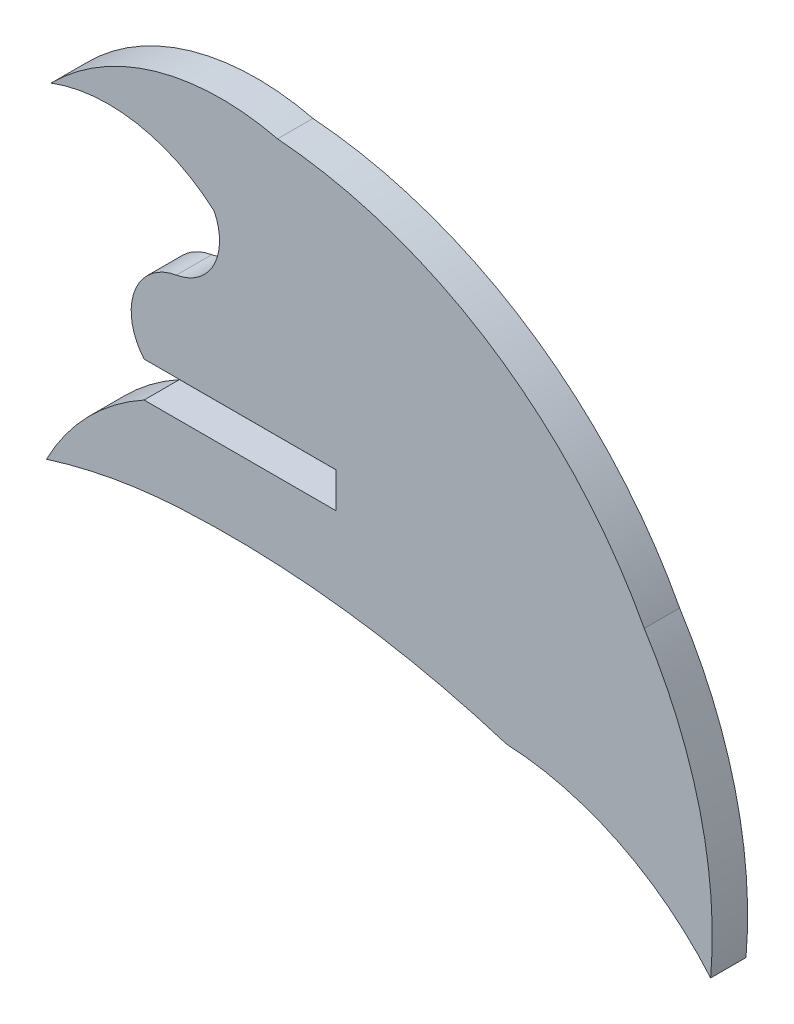
from build123d import *

# Parameters (mm, degrees)
BOSS_EXTRUDE1_DEPTH = 1.524


with BuildPart() as part:
    # Sketch1 → Boss-Extrude1 (new body)
    with BuildSketch(Plane.XY):
        with BuildLine():
            Line((-10.900934465, -3.68364082), (-2.635951713, -3.681036987))
            Line((-2.635951713, -3.681036987), (-2.635951713, -2.155055787))
            Line((-2.635951713, -2.155055787), (-10.901683213, -2.157042615))
            ThreePointArc((-10.901683213, -2.157042615), (-11.317544758, 0.15997729), (-9.511729503, 1.670127391))
            ThreePointArc((-9.511729503, 1.670127391), (-7.892680295, 2.86711895), (-7.885754316, 4.88058888))
            ThreePointArc((-7.885754316, 4.88058888), (-11.223059029, 6.479724486), (-14.907398818, 6.132625428))
            ThreePointArc((-14.907398818, 6.132625428), (-10.400280149, 8.822736649), (-5.152538869, 8.932411295))
            ThreePointArc((-5.152538869, 8.932411295), (4.07543143, 5.777326615), (10.640409761, -1.4345424))
            ThreePointArc((10.640409761, -1.4345424), (13.031939874, -7.001943531), (13.500316897, -13.04313502))
            ThreePointArc((13.500316897, -13.04313502), (9.547445937, -9.965660072), (4.697121946, -8.71250483))
            ThreePointArc((4.697121946, -8.71250483), (-2.219244662, -7.205435551), (-9.293116928, -6.945212506))
            ThreePointArc((-9.293116928, -6.945212506), (-12.232846335, -7.286099179), (-15.105972143, -7.995578426))
            ThreePointArc((-15.105972143, -7.995578426), (-13.323913323, -5.527094328), (-10.900934465, -3.68364082))
        make_face()
    extrude(amount=BOSS_EXTRUDE1_DEPTH)


solid = part.part
